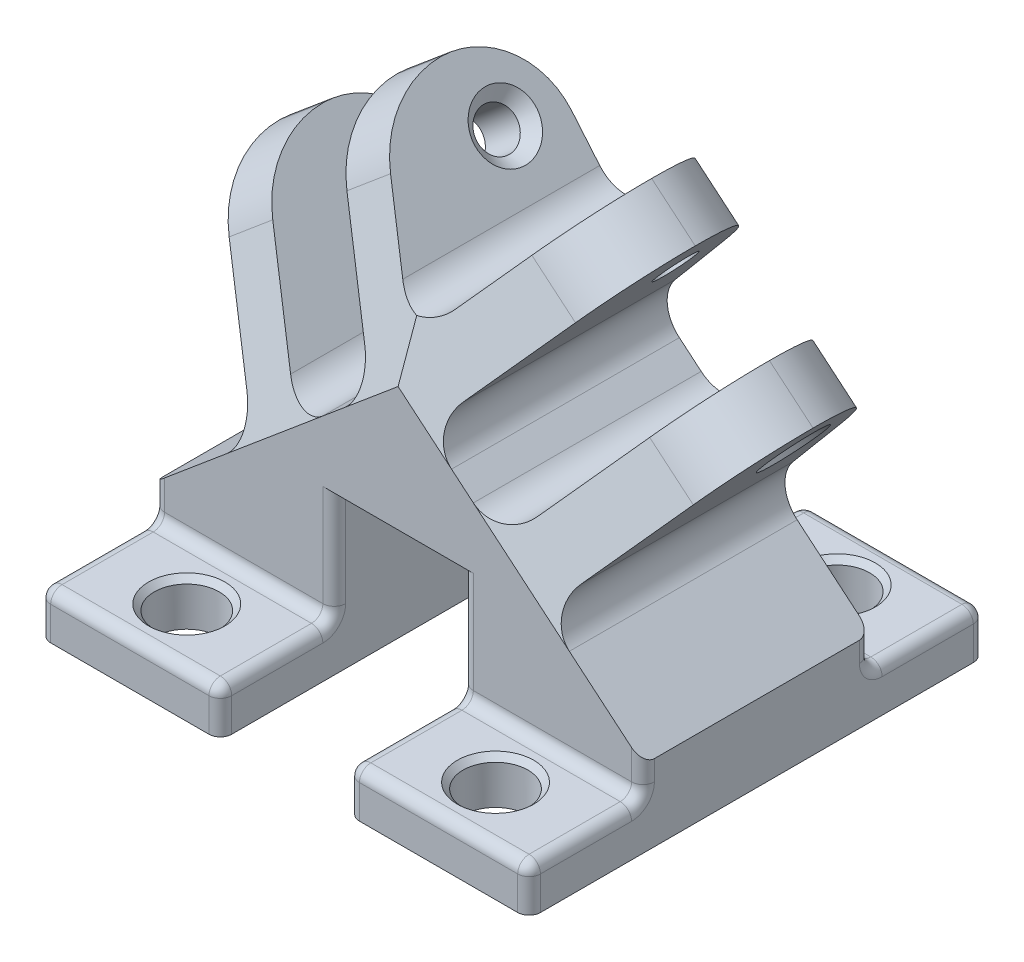
from build123d import *

# Parameters (mm, degrees)
BOSS_EXTRUDE1_DEPTH = 20
SKETCH5_R           = 1.75
CUT_EXTRUDE3_DEPTH  = 45.590264942
SKETCH6_R           = 1.75
CUT_EXTRUDE4_DEPTH  = 45.590264942
CUT_EXTRUDE5_DEPTH  = 45.590264942
CUT_EXTRUDE6_DEPTH  = 45.590264942
BOSS_EXTRUDE3_DEPTH = 10
SKETCH10_R          = 2.85
CUT_EXTRUDE7_DEPTH  = 4.933726003
BOSS_EXTRUDE4_DEPTH = 10
SKETCH12_R          = 2.85
CUT_EXTRUDE8_DEPTH  = 4.933726003
CUT_EXTRUDE9_DEPTH  = 41
CHAMFER1_SIZE       = 1
CHAMFER2_SIZE       = 0.5
FILLET1_R           = 1
FILLET2_R           = 3


with BuildPart() as part:
    # Sketch1 → Boss-Extrude1 (new body)
    with BuildSketch(Plane.XY):
        Polygon((-16.499999997, 0), (-0.605600394, 0), (-0.605600394, 13.845143912), (10.605600394, 13.845143912), (10.605600394, 0), (26.499999997, 0), (29.800788035, 3.933726003), (17.736610648, 14.0567728), (28.429456198, 26.800009899), (24.599233982, 30.013947947), (13.906388432, 17.270710848), (7.395010666, 22.73440553), (18.087856216, 35.47764263), (14.257634, 38.691580678), (5, 27.658762099), (-4.257634, 38.691580678), (-8.087856216, 35.47764263), (2.604989334, 22.73440553), (-3.906388432, 17.270710848), (-14.599233982, 30.013947947), (-18.429456198, 26.800009899), (-7.736610648, 14.0567728), (-19.800788035, 3.933726003), align=None)
    extrude(amount=BOSS_EXTRUDE1_DEPTH)

    # Sketch5 → Cut-Extrude3 (cut, through all)
    with BuildSketch(Plane(origin=(2.381579924, 1.998382835, 0), x_dir=(0, 0, 1), z_dir=(-0.766044443, -0.64278761, 0))):
        with Locations((5.02612125, 26.624225366)):
            Circle(SKETCH5_R)
    extrude(amount=-CUT_EXTRUDE3_DEPTH, mode=Mode.SUBTRACT)

    # Sketch6 → Cut-Extrude4 (cut, through all)
    with BuildSketch(Plane(origin=(3.486660965, -2.92565593, 0), x_dir=(0, 0, -1), z_dir=(0.766044443, -0.64278761, 0))):
        with Locations((-5.02612125, 33.052101463)):
            Circle(SKETCH6_R)
    extrude(amount=-CUT_EXTRUDE4_DEPTH, mode=Mode.SUBTRACT)

    # Sketch7 → Cut-Extrude5 (cut, through all)
    with BuildSketch(Plane(origin=(2.381579924, 1.998382835, 0), x_dir=(0, 0, 1), z_dir=(-0.766044443, -0.64278761, 0))):
        with BuildLine():
            ThreePointArc((0, 25.376224756), (2.050252532, 30.325972224), (7, 32.376224756))
            Line((7, 32.376224756), (0, 32.376224756))
            Line((0, 32.376224756), (0, 25.376224756))
        make_face()
        with BuildLine():
            ThreePointArc((7, 32.376224756), (11.421832756, 31.087378042), (14.458671842, 27.62452674))
            Line((14.458671842, 27.62452674), (20, 15.741110157))
            Line((20, 15.741110157), (20, 32.376224756))
            Line((20, 32.376224756), (7, 32.376224756))
        make_face()
    extrude(amount=-CUT_EXTRUDE5_DEPTH, mode=Mode.SUBTRACT)

    # Sketch8 → Cut-Extrude6 (cut, through all)
    with BuildSketch(Plane(origin=(3.486660965, -2.92565593, 0), x_dir=(0, 0, -1), z_dir=(0.766044443, -0.64278761, 0))):
        with BuildLine():
            Line((-20, 22.168986254), (-14.458671842, 34.052402837))
            ThreePointArc((-14.458671842, 34.052402837), (-11.421832756, 37.515254138), (-7, 38.804100853))
            Line((-7, 38.804100853), (-20, 38.804100853))
            Line((-20, 38.804100853), (-20, 22.168986254))
        make_face()
        with BuildLine():
            Line((0, 38.804100853), (-7, 38.804100853))
            ThreePointArc((-7, 38.804100853), (-2.050252532, 36.753848321), (0, 31.804100853))
            Line((0, 31.804100853), (0, 38.804100853))
        make_face()
    extrude(amount=-CUT_EXTRUDE6_DEPTH, mode=Mode.SUBTRACT)

    # Sketch9 → Boss-Extrude3 (add)
    with BuildSketch(Plane.XY.offset(20)):
        Polygon((-0.605600394, 0), (-16.499999997, 0), (-19.800788035, 3.933726003), (-0.605600394, 3.933726003), align=None)
        Polygon((10.605600394, 3.933726003), (10.605600394, 0), (26.499999997, 0), (29.800788035, 3.933726003), align=None)
    extrude(amount=BOSS_EXTRUDE3_DEPTH)

    # Sketch10 → Cut-Extrude7 (cut, through all)
    with BuildSketch(Plane(origin=(0, 3.933726003, 0), x_dir=(1, 0, 0), z_dir=(0, 1, 0))):
        with Locations((-8.552800195, -25)):
            Circle(SKETCH10_R)
        with Locations((18.552800195, -25)):
            Circle(SKETCH10_R)
    extrude(amount=-CUT_EXTRUDE7_DEPTH, mode=Mode.SUBTRACT)

    # Sketch11 → Boss-Extrude4 (add)
    with BuildSketch(Plane(origin=(0, 0, 0), x_dir=(-1, 0, 0), z_dir=(0, 0, -1))):
        Polygon((19.800788035, 3.933726003), (16.499999997, 0), (0.605600394, 0), (0.605600394, 3.933726003), align=None)
        Polygon((-10.605600394, 3.933726003), (-10.605600394, 0), (-26.499999997, 0), (-29.800788035, 3.933726003), align=None)
    extrude(amount=BOSS_EXTRUDE4_DEPTH)

    # Sketch12 → Cut-Extrude8 (cut, through all)
    with BuildSketch(Plane(origin=(0, 3.933726003, 0), x_dir=(1, 0, 0), z_dir=(0, 1, 0))):
        with Locations((-8.552800195, 5)):
            Circle(SKETCH12_R)
        with Locations((18.552800195, 5)):
            Circle(SKETCH12_R)
    extrude(amount=-CUT_EXTRUDE8_DEPTH, mode=Mode.SUBTRACT)

    # Sketch13 → Cut-Extrude9 (cut, through all)
    with BuildSketch(Plane.XY.offset(30)):
        Polygon((-16.499999997, 0), (-16.499999997, 3.933726003), (-16.499999997, 6.703416029), (-19.800788035, 3.933726003), align=None)
        Polygon((26.499999997, 0), (26.499999997, 3.933726003), (26.499999997, 6.703416029), (29.800788035, 3.933726003), align=None)
    extrude(amount=-CUT_EXTRUDE9_DEPTH, mode=Mode.SUBTRACT)

    # Chamfer1
    chamfer1_edges = [part.edges().sort_by_distance(p)[0] for p in [
        (-0.560320061, 34.285293508, 3.27612125),
        (-14.732142259, 22.393722729, 3.27612125),
        (10.560320061, 34.285293508, 6.77612125),
        (24.732142259, 22.393722729, 6.77612125),
    ]]
    chamfer(chamfer1_edges, length=CHAMFER1_SIZE)

    # Chamfer2
    chamfer2_edges = [part.edges().sort_by_distance(p)[0] for p in [
        (-11.402800195, 3.933726003, 25),
        (15.702800195, 3.933726003, 25),
        (15.702800195, 3.933726003, -5),
        (-11.402800195, 3.933726003, -5),
    ]]
    chamfer(chamfer2_edges, length=CHAMFER2_SIZE)

    # Fillet1
    fillet1_edges = [part.edges().sort_by_distance(p)[0] for p in [
        (-0.605600394, 8.889434958, 20),
        (10.605600394, 8.889434958, 20),
        (-8.552800195, 3.933726003, 20),
        (-0.605600394, 3.933726003, 25),
        (-0.605600394, 1.966863002, 30),
        (-8.552800195, 3.933726003, 30),
        (10.605600394, 3.933726003, 25),
        (10.605600394, 1.966863002, 30),
        (10.605600394, 8.889434958, 0),
        (-0.605600394, 8.889434958, 0),
        (-0.605600394, 3.933726003, -5),
        (-0.605600394, 1.966863002, -10),
        (18.552800195, 3.933726003, 0),
        (10.605600394, 3.933726003, -5),
        (18.552800195, 3.933726003, -10),
        (10.605600394, 1.966863002, -10),
        (26.499999997, 1.966863002, -10),
        (-8.552800195, 3.933726003, -10),
        (-8.552800195, 3.933726003, 0),
        (18.552800195, 3.933726003, 30),
        (18.552800195, 3.933726003, 20),
        (26.499999997, 1.966863002, 30),
        (26.499999997, 5.318571016, 20),
        (26.499999997, 5.318571016, 0),
        (26.499999997, 3.933726003, -5),
        (26.499999997, 3.933726003, 25),
        (-16.499999997, 1.966863002, 30),
        (-16.499999997, 5.318571016, 20),
        (-16.499999997, 3.933726003, 25),
        (-16.499999997, 1.966863002, -10),
        (-16.499999997, 3.933726003, -5),
        (-16.499999997, 5.318571016, 0),
    ]]
    fillet(fillet1_edges, radius=FILLET1_R)

    # Fillet2
    fillet2_edges = [part.edges().sort_by_distance(p)[0] for p in [
        (5, 27.658762099, 9.479415808),
        (-7.736610648, 14.0567728, 10),
        (-3.906388432, 17.270710848, 10),
        (2.604989334, 22.73440553, 10),
        (7.395010666, 22.73440553, 10),
        (13.906388432, 17.270710848, 10),
        (17.736610648, 14.0567728, 10),
    ]]
    fillet(fillet2_edges, radius=FILLET2_R)


solid = part.part
